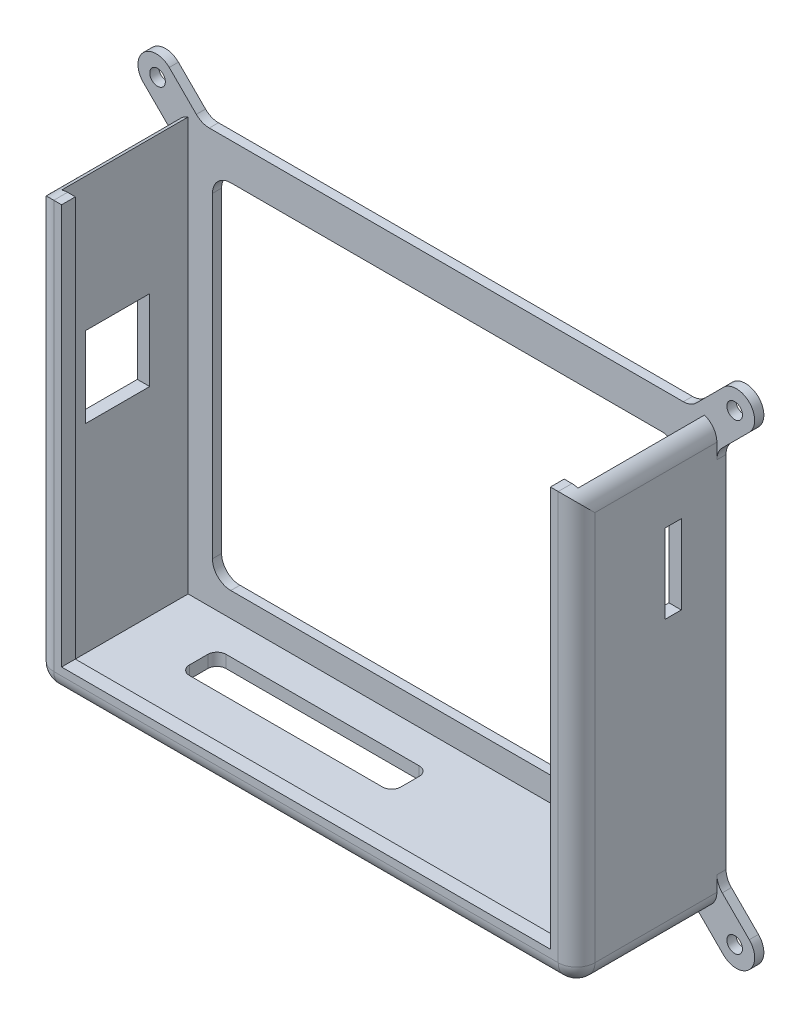
from build123d import *

# Parameters (mm, degrees)
SKETCH1_W            = 102
SKETCH1_H            = 77
BOSS_EXTRUDE1_DEPTH  = 2
BOSS_EXTRUDE2_DEPTH  = 27.6
FILLET1_R            = 4
FILLET3_R            = 4
M3_CLEARANCE_HOLE1_D = 3.4
BOSS_EXTRUDE3_DEPTH  = 3
FILLET4_R            = 4
SKETCH6_W            = 14
SKETCH6_H            = 17.55
CUT_EXTRUDE1_DEPTH   = 5
SKETCH8_W            = 46.1
SKETCH8_H            = 8
CUT_EXTRUDE3_DEPTH   = 5
SKETCH9_W            = 3.59
SKETCH9_H            = 17.24
CUT_EXTRUDE4_DEPTH   = 5
FILLET5_R            = 2


with BuildPart() as part:
    # Sketch1 → Boss-Extrude1 (new body)
    with BuildSketch(Plane.XY):
        with BuildLine():
            Line((5.656854249, 0), (112.343145751, 0))
            Line((112.343145751, 0), (119.414213562, -7.071067812))
            ThreePointArc((119.414213562, -7.071067812), (125.071067812, -7.071067812), (125.071067812, -1.414213562))
            Line((125.071067812, -1.414213562), (118, 5.656854249))
            Line((118, 5.656854249), (118, 87.343145751))
            Line((118, 87.343145751), (125.071067812, 94.414213562))
            ThreePointArc((125.071067812, 94.414213562), (125.071067812, 100.071067812), (119.414213562, 100.071067812))
            Line((119.414213562, 100.071067812), (112.343145751, 93))
            Line((112.343145751, 93), (5.656854249, 93))
            Line((5.656854249, 93), (-1.414213562, 100.071067812))
            ThreePointArc((-1.414213562, 100.071067812), (-7.071067812, 100.071067812), (-7.071067812, 94.414213562))
            Line((-7.071067812, 94.414213562), (0, 87.343145751))
            Line((0, 87.343145751), (0, 5.656854249))
            Line((0, 5.656854249), (-7.071067812, -1.414213562))
            ThreePointArc((-7.071067812, -1.414213562), (-7.071067812, -7.071067812), (-1.414213562, -7.071067812))
            Line((-1.414213562, -7.071067812), (5.656854249, 0))
        make_face()
        with Locations((59, 46.5)):
            Rectangle(SKETCH1_W, SKETCH1_H, mode=Mode.SUBTRACT)
    extrude(amount=BOSS_EXTRUDE1_DEPTH)

    # Sketch2 → Boss-Extrude2 (add)
    with BuildSketch(Plane.XY.offset(2)):
        Polygon((0, 93), (0, 0), (118, 0), (118, 93), (115.3, 93), (115.3, 2.7), (2.7, 2.7), (2.7, 93), align=None)
    extrude(amount=BOSS_EXTRUDE2_DEPTH)

    # Fillet1
    fillet1_edges = [part.edges().sort_by_distance(p)[0] for p in [
        (8, 85, 1),
        (8, 8, 1),
        (110, 8, 1),
        (110, 85, 1),
    ]]
    fillet(fillet1_edges, radius=FILLET1_R)

    # Fillet3
    fillet3_edges = [part.edges().sort_by_distance(p)[0] for p in [
        (112.343145751, 0, 1),
        (5.656854249, 0, 1),
        (0, 5.656854249, 1),
        (0, 87.343145751, 1),
        (5.656854249, 93, 1),
        (112.343145751, 93, 1),
        (118, 87.343145751, 1),
        (118, 5.656854249, 1),
    ]]
    fillet(fillet3_edges, radius=FILLET3_R)

    # M3 Clearance Hole1 (through all)
    with Locations(Plane.XY.offset(2)):
        with Locations((-3.972495555, 96.92383124), (121.87433229, 96.92383124), (121.87433229, -3.91357469), (-3.972495555, -3.91357469)):
            Hole(M3_CLEARANCE_HOLE1_D / 2)

    # Sketch5 → Boss-Extrude3 (add)
    with BuildSketch(Plane.XY.offset(29.6)):
        Polygon((0, 93), (5.7, 93), (5.7, 5.7), (112.3, 5.7), (112.3, 93), (118, 93), (118, 0), (0, 0), align=None)
    extrude(amount=BOSS_EXTRUDE3_DEPTH)

    # Fillet4
    fillet4_edges = [part.edges().sort_by_distance(p)[0] for p in [
        (0, 0, 17.3),
        (118, 0, 17.3),
        (118, 93, 17.3),
        (0, 93, 17.3),
        (59, 0, 32.6),
        (118, 46.5, 32.6),
        (0, 46.5, 32.6),
    ]]
    fillet(fillet4_edges, radius=FILLET4_R)

    # Sketch6 → Cut-Extrude1 (cut)
    with BuildSketch(Plane.ZY):
        with Locations((17.37699989, 54.836937287)):
            Rectangle(SKETCH6_W, SKETCH6_H)
    extrude(amount=-CUT_EXTRUDE1_DEPTH, mode=Mode.SUBTRACT)

    # Sketch8 → Cut-Extrude3 (cut)
    with BuildSketch(Plane.XZ):
        with Locations((39.295, 13.26259989)):
            Rectangle(SKETCH8_W, SKETCH8_H)
    extrude(amount=-CUT_EXTRUDE3_DEPTH, mode=Mode.SUBTRACT)

    # Sketch9 → Cut-Extrude4 (cut)
    with BuildSketch(Plane(origin=(118, 0, 0), x_dir=(0, 0, -1), z_dir=(1, 0, 0))):
        with Locations((-11.55759989, 69.828337287)):
            Rectangle(SKETCH9_W, SKETCH9_H)
    extrude(amount=-CUT_EXTRUDE4_DEPTH, mode=Mode.SUBTRACT)

    # Fillet5
    fillet5_edges = [part.edges().sort_by_distance(p)[0] for p in [
        (16.245, 1.35, 9.26259989),
        (16.245, 1.35, 17.26259989),
        (62.345, 1.35, 17.26259989),
        (62.345, 1.35, 9.26259989),
    ]]
    fillet(fillet5_edges, radius=FILLET5_R)


solid = part.part
